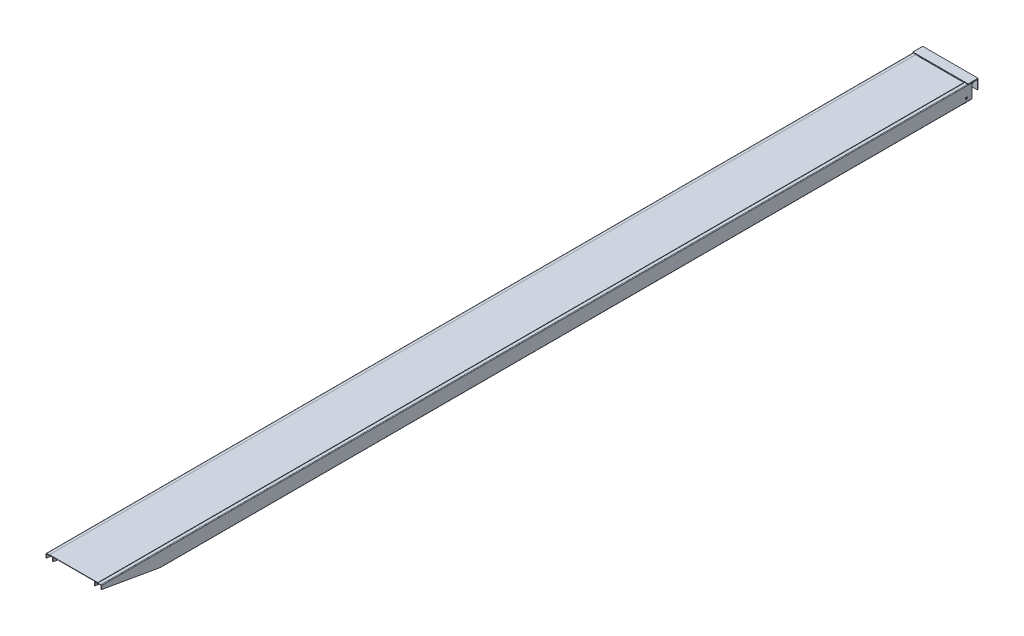
from build123d import *

# Parameters (mm, degrees)
SKETCH1_W                             = 240
SKETCH1_H                             = 4350
BOSS_EXTRUDE1_DEPTH                   = 2
STRUCTURAL_MEMBER1_DEPTH              = 4350
STRUCTURAL_MEMBER1_2_DEPTH            = 4350
CUT_EXTRUDEMAINRAILPROFILE_DEPTH      = 2181.619767979
CUT_EXTRUDEMAINRAILPROFILE_DEPTH_BACK = 2181.619767979
STRUCTURAL_MEMBER2_DEPTH              = 205.5
STRUCTURAL_MEMBER2_2_DEPTH            = 205.5
STRUCTURAL_MEMBER2_3_DEPTH            = 205.5
STRUCTURAL_MEMBER2_4_DEPTH            = 205.5
SKETCH13_W                            = 268.5
SKETCH13_H                            = 50
CUT_EXTRUDETREADCLEARANCE_DEPTH       = 2
BOSS_EXTRUDEANGLEIRON_START           = -137.25
BOSS_EXTRUDEANGLEIRON_DEPTH           = 274.5
CUT_EXTRUDEWHEELHOLES_START           = -3
SKETCH15_W                            = 30.1
SKETCH15_H                            = 123.311564932
CUT_EXTRUDEWHEELHOLES_DEPTH           = 3
SKETCH16_R                            = 5
CUT_EXTRUDEAXLEHOLES_DEPTH            = 2184.612047169
CUT_EXTRUDEAXLEHOLES_DEPTH_BACK       = 2184.612047169
BOSS_EXTRUDELEFTWHEEL_START           = -109
SKETCH16_3_R                          = 25
SKETCH16_3_R_2                        = 5
BOSS_EXTRUDELEFTWHEEL_DEPTH           = 22
BOSS_EXTRUDERIGHTWHEEL_START          = 109
SKETCH16_4_R                          = 25
SKETCH16_4_R_2                        = 5
BOSS_EXTRUDERIGHTWHEEL_DEPTH          = 22


with BuildPart() as part:
    # Sketch1 → Boss-Extrude1 (new body)
    with BuildSketch(Plane(origin=(0, 0, 0), x_dir=(1, 0, 0), z_dir=(0, 1, 0))):
        Rectangle(SKETCH1_W, SKETCH1_H)
    extrude(amount=-BOSS_EXTRUDE1_DEPTH)

    # Sketch13 → Cut-ExtrudeTreadClearance (cut)
    with BuildSketch(Plane(origin=(0, 0, 0), x_dir=(1, 0, 0), z_dir=(0, 1, 0))):
        with Locations((0, 2150)):
            Rectangle(SKETCH13_W, SKETCH13_H)
    extrude(amount=-CUT_EXTRUDETREADCLEARANCE_DEPTH, mode=Mode.SUBTRACT)


with BuildPart() as body_2:
    # Sketch111 → Structural Member1 (new body)
    with BuildSketch(Plane(origin=(-120, -38.55, -2175), x_dir=(-1, 0, 0), z_dir=(0, 0, 1))):
        with BuildLine():
            Line((-14.25, 36.55), (14.25, 36.55))
            ThreePointArc((14.25, 36.55), (16.371320344, 35.671320344), (17.25, 33.55))
            Line((17.25, 33.55), (17.25, -33.55))
            ThreePointArc((17.25, -33.55), (16.371320344, -35.671320344), (14.25, -36.55))
            Line((14.25, -36.55), (-14.25, -36.55))
            ThreePointArc((-14.25, -36.55), (-16.371320344, -35.671320344), (-17.25, -33.55))
            Line((-17.25, -33.55), (-17.25, 33.55))
            ThreePointArc((-17.25, 33.55), (-16.371320344, 35.671320344), (-14.25, 36.55))
        make_face()
        with BuildLine():
            Line((-14.25, 34.35), (14.25, 34.35))
            ThreePointArc((14.25, 34.35), (14.815685425, 34.115685425), (15.05, 33.55))
            Line((15.05, 33.55), (15.05, -33.55))
            ThreePointArc((15.05, -33.55), (14.815685425, -34.115685425), (14.25, -34.35))
            Line((14.25, -34.35), (-14.25, -34.35))
            ThreePointArc((-14.25, -34.35), (-14.815685425, -34.115685425), (-15.05, -33.55))
            Line((-15.05, -33.55), (-15.05, 33.55))
            ThreePointArc((-15.05, 33.55), (-14.815685425, 34.115685425), (-14.25, 34.35))
        make_face(mode=Mode.SUBTRACT)
    extrude(amount=STRUCTURAL_MEMBER1_DEPTH)


with BuildPart() as body_3:
    # Sketch111 on segment 2 (carried to segment 2) → Structural Member1 2 (new body)
    with BuildSketch(Plane(origin=(120, -38.55, -2175), x_dir=(-1, 0, 0), z_dir=(0, 0, 1))):
        with BuildLine():
            Line((-14.25, 36.55), (14.25, 36.55))
            ThreePointArc((14.25, 36.55), (16.371320344, 35.671320344), (17.25, 33.55))
            Line((17.25, 33.55), (17.25, -33.55))
            ThreePointArc((17.25, -33.55), (16.371320344, -35.671320344), (14.25, -36.55))
            Line((14.25, -36.55), (-14.25, -36.55))
            ThreePointArc((-14.25, -36.55), (-16.371320344, -35.671320344), (-17.25, -33.55))
            Line((-17.25, -33.55), (-17.25, 33.55))
            ThreePointArc((-17.25, 33.55), (-16.371320344, 35.671320344), (-14.25, 36.55))
        make_face()
        with BuildLine():
            Line((-14.25, 34.35), (14.25, 34.35))
            ThreePointArc((14.25, 34.35), (14.815685425, 34.115685425), (15.05, 33.55))
            Line((15.05, 33.55), (15.05, -33.55))
            ThreePointArc((15.05, -33.55), (14.815685425, -34.115685425), (14.25, -34.35))
            Line((14.25, -34.35), (-14.25, -34.35))
            ThreePointArc((-14.25, -34.35), (-14.815685425, -34.115685425), (-15.05, -33.55))
            Line((-15.05, -33.55), (-15.05, 33.55))
            ThreePointArc((-15.05, 33.55), (-14.815685425, 34.115685425), (-14.25, 34.35))
        make_face(mode=Mode.SUBTRACT)
    extrude(amount=STRUCTURAL_MEMBER1_2_DEPTH)


with BuildPart() as cut_extrudemainrailprofile_tool:
    # Sketch12 → Cut-ExtrudeMainRailProfile (new, two sides)
    with BuildSketch(Plane(origin=(0, 0, 0), x_dir=(0, 0, -1), z_dir=(1, 0, 0))) as cut_extrudemainrailprofile_sk:
        with BuildLine():
            Line((2148, -17.5), (2148, -66.336204728))
            ThreePointArc((2148, -66.336204728), (2145.071067812, -73.40727254), (2138, -76.336204728))
            Line((2138, -76.336204728), (2114.970377619, -76.336204728))
            Line((2114.970377619, -76.336204728), (2114.970377619, -175.544193155))
            Line((2114.970377619, -175.544193155), (2148, -175.544193155))
            Line((2148, -175.544193155), (2316.135646249, -175.544193155))
            Line((2316.135646249, -175.544193155), (2316.135646249, -4))
            Line((2316.135646249, -4), (2161.5, -4))
            ThreePointArc((2161.5, -4), (2151.954058454, -7.954058454), (2148, -17.5))
        make_face()
        Polygon((-2316.135646249, -4), (-2274.918485807, -4.545150239), (-1874.918485807, -74.395150239), (-1874.918485807, -175.544193155), (-2316.135646249, -175.544193155), align=None)
    extrude(amount=CUT_EXTRUDEMAINRAILPROFILE_DEPTH)
    extrude(cut_extrudemainrailprofile_sk.sketch, amount=-CUT_EXTRUDEMAINRAILPROFILE_DEPTH_BACK)


with BuildPart() as body_2_1:
    add(body_2.part)

    # Cut-ExtrudeMainRailProfile: cut by cut_extrudemainrailprofile_tool
    add(cut_extrudemainrailprofile_tool.part, mode=Mode.SUBTRACT)


with BuildPart() as body_3_1:
    add(body_3.part)

    # Cut-ExtrudeMainRailProfile: cut by cut_extrudemainrailprofile_tool
    add(cut_extrudemainrailprofile_tool.part, mode=Mode.SUBTRACT)


with BuildPart() as body_4:
    # Sketch19 → Structural Member2 (new body)
    with BuildSketch(Plane(origin=(-102.75, -19.8, 1824.918485807), x_dir=(0, 0, 1), z_dir=(1, 0, 0))):
        with BuildLine():
            Line((-14.8, -17.8), (14.8, -17.8))
            ThreePointArc((14.8, -17.8), (16.921320344, -16.921320344), (17.8, -14.8))
            Line((17.8, -14.8), (17.8, 14.8))
            ThreePointArc((17.8, 14.8), (16.921320344, 16.921320344), (14.8, 17.8))
            Line((14.8, 17.8), (-14.8, 17.8))
            ThreePointArc((-14.8, 17.8), (-16.921320344, 16.921320344), (-17.8, 14.8))
            Line((-17.8, 14.8), (-17.8, -14.8))
            ThreePointArc((-17.8, -14.8), (-16.921320344, -16.921320344), (-14.8, -17.8))
        make_face()
        with BuildLine():
            Line((-14.8, 16.6), (14.8, 16.6))
            ThreePointArc((14.8, 16.6), (16.072792206, 16.072792206), (16.6, 14.8))
            Line((16.6, 14.8), (16.6, -14.8))
            ThreePointArc((16.6, -14.8), (16.072792206, -16.072792206), (14.8, -16.6))
            Line((14.8, -16.6), (-14.8, -16.6))
            ThreePointArc((-14.8, -16.6), (-16.072792206, -16.072792206), (-16.6, -14.8))
            Line((-16.6, -14.8), (-16.6, 14.8))
            ThreePointArc((-16.6, 14.8), (-16.072792206, 16.072792206), (-14.8, 16.6))
        make_face(mode=Mode.SUBTRACT)
    extrude(amount=STRUCTURAL_MEMBER2_DEPTH)


with BuildPart() as body_5:
    # Sketch19 on segment 2 (carried to segment 2) → Structural Member2 2 (new body)
    with BuildSketch(Plane(origin=(-102.75, -19.8, 524.945657205), x_dir=(0, 0, 1), z_dir=(1, 0, 0))):
        with BuildLine():
            Line((-14.8, -17.8), (14.8, -17.8))
            ThreePointArc((14.8, -17.8), (16.921320344, -16.921320344), (17.8, -14.8))
            Line((17.8, -14.8), (17.8, 14.8))
            ThreePointArc((17.8, 14.8), (16.921320344, 16.921320344), (14.8, 17.8))
            Line((14.8, 17.8), (-14.8, 17.8))
            ThreePointArc((-14.8, 17.8), (-16.921320344, 16.921320344), (-17.8, 14.8))
            Line((-17.8, 14.8), (-17.8, -14.8))
            ThreePointArc((-17.8, -14.8), (-16.921320344, -16.921320344), (-14.8, -17.8))
        make_face()
        with BuildLine():
            Line((-14.8, 16.6), (14.8, 16.6))
            ThreePointArc((14.8, 16.6), (16.072792206, 16.072792206), (16.6, 14.8))
            Line((16.6, 14.8), (16.6, -14.8))
            ThreePointArc((16.6, -14.8), (16.072792206, -16.072792206), (14.8, -16.6))
            Line((14.8, -16.6), (-14.8, -16.6))
            ThreePointArc((-14.8, -16.6), (-16.072792206, -16.072792206), (-16.6, -14.8))
            Line((-16.6, -14.8), (-16.6, 14.8))
            ThreePointArc((-16.6, 14.8), (-16.072792206, 16.072792206), (-14.8, 16.6))
        make_face(mode=Mode.SUBTRACT)
    extrude(amount=STRUCTURAL_MEMBER2_2_DEPTH)


with BuildPart() as body_6:
    # Sketch19 on segment 3 (carried to segment 3) → Structural Member2 3 (new body)
    with BuildSketch(Plane(origin=(-102.75, -19.8, -775.027171398), x_dir=(0, 0, 1), z_dir=(1, 0, 0))):
        with BuildLine():
            Line((-14.8, -17.8), (14.8, -17.8))
            ThreePointArc((14.8, -17.8), (16.921320344, -16.921320344), (17.8, -14.8))
            Line((17.8, -14.8), (17.8, 14.8))
            ThreePointArc((17.8, 14.8), (16.921320344, 16.921320344), (14.8, 17.8))
            Line((14.8, 17.8), (-14.8, 17.8))
            ThreePointArc((-14.8, 17.8), (-16.921320344, 16.921320344), (-17.8, 14.8))
            Line((-17.8, 14.8), (-17.8, -14.8))
            ThreePointArc((-17.8, -14.8), (-16.921320344, -16.921320344), (-14.8, -17.8))
        make_face()
        with BuildLine():
            Line((-14.8, 16.6), (14.8, 16.6))
            ThreePointArc((14.8, 16.6), (16.072792206, 16.072792206), (16.6, 14.8))
            Line((16.6, 14.8), (16.6, -14.8))
            ThreePointArc((16.6, -14.8), (16.072792206, -16.072792206), (14.8, -16.6))
            Line((14.8, -16.6), (-14.8, -16.6))
            ThreePointArc((-14.8, -16.6), (-16.072792206, -16.072792206), (-16.6, -14.8))
            Line((-16.6, -14.8), (-16.6, 14.8))
            ThreePointArc((-16.6, 14.8), (-16.072792206, 16.072792206), (-14.8, 16.6))
        make_face(mode=Mode.SUBTRACT)
    extrude(amount=STRUCTURAL_MEMBER2_3_DEPTH)


with BuildPart() as body_7:
    # Sketch19 on segment 4 (carried to segment 4) → Structural Member2 4 (new body)
    with BuildSketch(Plane(origin=(-102.75, -19.8, -2075), x_dir=(0, 0, 1), z_dir=(1, 0, 0))):
        with BuildLine():
            Line((-14.8, -17.8), (14.8, -17.8))
            ThreePointArc((14.8, -17.8), (16.921320344, -16.921320344), (17.8, -14.8))
            Line((17.8, -14.8), (17.8, 14.8))
            ThreePointArc((17.8, 14.8), (16.921320344, 16.921320344), (14.8, 17.8))
            Line((14.8, 17.8), (-14.8, 17.8))
            ThreePointArc((-14.8, 17.8), (-16.921320344, 16.921320344), (-17.8, 14.8))
            Line((-17.8, 14.8), (-17.8, -14.8))
            ThreePointArc((-17.8, -14.8), (-16.921320344, -16.921320344), (-14.8, -17.8))
        make_face()
        with BuildLine():
            Line((-14.8, 16.6), (14.8, 16.6))
            ThreePointArc((14.8, 16.6), (16.072792206, 16.072792206), (16.6, 14.8))
            Line((16.6, 14.8), (16.6, -14.8))
            ThreePointArc((16.6, -14.8), (16.072792206, -16.072792206), (14.8, -16.6))
            Line((14.8, -16.6), (-14.8, -16.6))
            ThreePointArc((-14.8, -16.6), (-16.072792206, -16.072792206), (-16.6, -14.8))
            Line((-16.6, -14.8), (-16.6, 14.8))
            ThreePointArc((-16.6, 14.8), (-16.072792206, 16.072792206), (-14.8, 16.6))
        make_face(mode=Mode.SUBTRACT)
    extrude(amount=STRUCTURAL_MEMBER2_4_DEPTH)


with BuildPart() as body_8:
    # Sketch14 → Boss-ExtrudeAngleIron (new body)
    with BuildSketch(Plane(origin=(0, 0, 0), x_dir=(0, 0, -1), z_dir=(1, 0, 0)).offset(BOSS_EXTRUDEANGLEIRON_START)):
        Polygon((2129, 1), (2178, 1), (2178, -48), (2175, -48), (2175, -2), (2129, -2), align=None)
    extrude(amount=BOSS_EXTRUDEANGLEIRON_DEPTH)


with BuildPart() as cut_extrudewheelholes_tool:
    # Sketch15 → Cut-ExtrudeWheelHoles (new body)
    with BuildSketch(Plane.XZ.offset(75.1).offset(CUT_EXTRUDEWHEELHOLES_START)):
        with Locations((-120, -2134.655782466)):
            Rectangle(SKETCH15_W, SKETCH15_H)
        with Locations((120, -2134.655782466)):
            Rectangle(SKETCH15_W, SKETCH15_H)
    extrude(amount=CUT_EXTRUDEWHEELHOLES_DEPTH)


with BuildPart() as body_2_2:
    add(body_2_1.part)

    # Cut-ExtrudeWheelHoles: cut by cut_extrudewheelholes_tool
    add(cut_extrudewheelholes_tool.part, mode=Mode.SUBTRACT)


with BuildPart() as body_3_2:
    add(body_3_1.part)

    # Cut-ExtrudeWheelHoles: cut by cut_extrudewheelholes_tool
    add(cut_extrudewheelholes_tool.part, mode=Mode.SUBTRACT)


with BuildPart() as cut_extrudeaxleholes_tool:
    # Sketch16 → Cut-ExtrudeAxleHoles (new, two sides)
    with BuildSketch(Plane(origin=(0, 0, 0), x_dir=(0, 0, -1), z_dir=(1, 0, 0))) as cut_extrudeaxleholes_sk:
        with Locations((2120, -56.1)):
            Circle(SKETCH16_R)
    extrude(amount=CUT_EXTRUDEAXLEHOLES_DEPTH)
    extrude(cut_extrudeaxleholes_sk.sketch, amount=-CUT_EXTRUDEAXLEHOLES_DEPTH_BACK)


with BuildPart() as body_2_3:
    add(body_2_2.part)

    # Cut-ExtrudeAxleHoles: cut by cut_extrudeaxleholes_tool
    add(cut_extrudeaxleholes_tool.part, mode=Mode.SUBTRACT)


with BuildPart() as body_3_3:
    add(body_3_2.part)

    # Cut-ExtrudeAxleHoles: cut by cut_extrudeaxleholes_tool
    add(cut_extrudeaxleholes_tool.part, mode=Mode.SUBTRACT)


with BuildPart() as body_9:
    # Sketch16_3 → Boss-ExtrudeLeftWheel (new body)
    with BuildSketch(Plane(origin=(0, 0, 0), x_dir=(0, 0, -1), z_dir=(1, 0, 0)).offset(BOSS_EXTRUDELEFTWHEEL_START)):
        with Locations((2120, -56.1)):
            Circle(SKETCH16_3_R)
        with Locations((2120, -56.1)):
            Circle(SKETCH16_3_R_2, mode=Mode.SUBTRACT)
    extrude(amount=-BOSS_EXTRUDELEFTWHEEL_DEPTH)


with BuildPart() as body_10:
    # Sketch16_4 → Boss-ExtrudeRightWheel (new body)
    with BuildSketch(Plane(origin=(0, 0, 0), x_dir=(0, 0, -1), z_dir=(1, 0, 0)).offset(BOSS_EXTRUDERIGHTWHEEL_START)):
        with Locations((2120, -56.1)):
            Circle(SKETCH16_4_R)
        with Locations((2120, -56.1)):
            Circle(SKETCH16_4_R_2, mode=Mode.SUBTRACT)
    extrude(amount=BOSS_EXTRUDERIGHTWHEEL_DEPTH)


solid = Compound([part.part, body_4.part, body_5.part, body_6.part, body_7.part, body_8.part, body_2_3.part, body_3_3.part, body_9.part, body_10.part])
